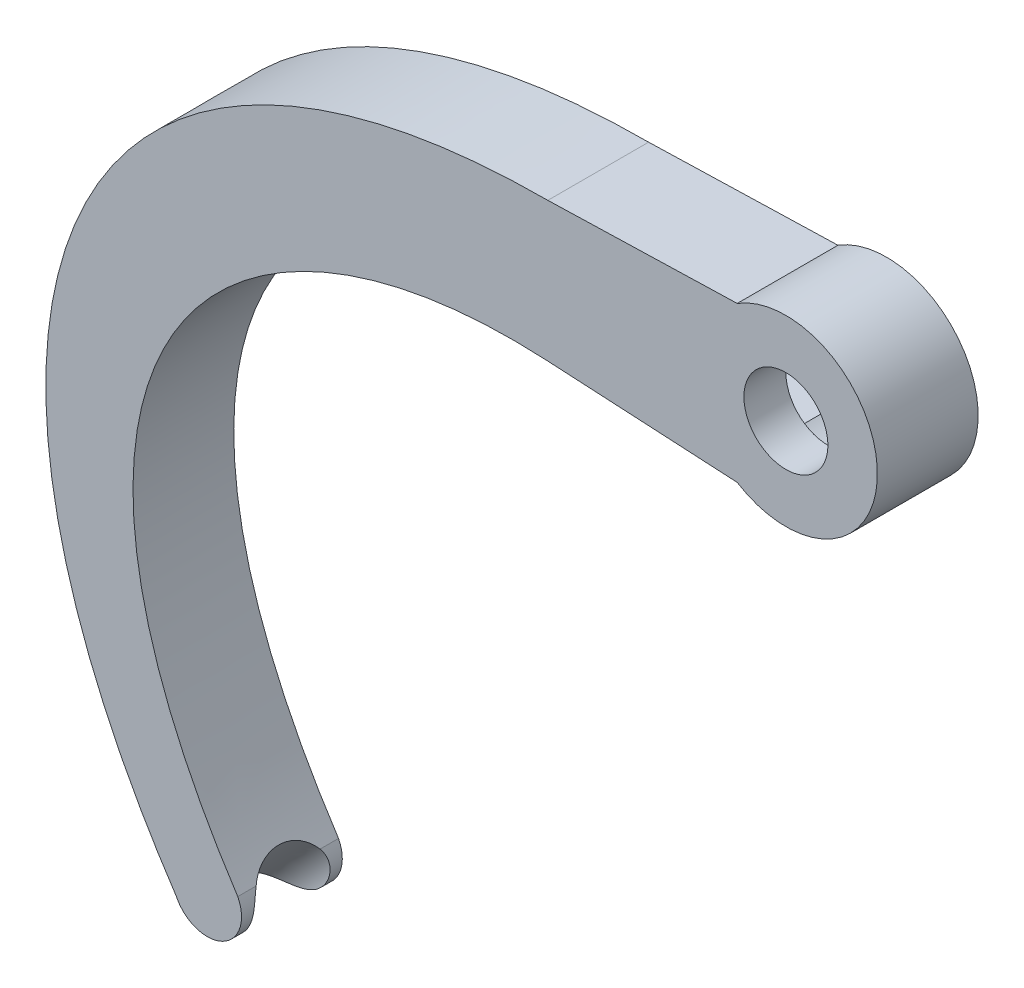
from build123d import *

# Parameters (mm, degrees)
BOSS_EXTRUDE1_DEPTH = 6
CUT_EXTRUDE1_DEPTH  = 3.5
SKETCH4_R           = 2.5
CUT_EXTRUDE2_DEPTH  = 3.5
SKETCH6_RX          = 2.368753343
SKETCH6_RY          = 2.322011883
CUT_EXTRUDE3_DEPTH  = 30


with BuildPart() as part:
    # Sketch1 → Boss-Extrude1 (new body)
    with BuildSketch(Plane.XY):
        with BuildLine():
            Line((-14.268243934, -3.994041761), (-2.898518265, -4.615310593))
            ThreePointArc((-2.898518265, -4.615310593), (5.45, 0), (-2.898518265, 4.615310593))
            Line((-2.898518265, 4.615310593), (-14.17529192, 4.292464798))
            add(Edge.make_bspline(
                [(-14.17529192, 4.292464798), (-42.462260129, 4.288818218), (-52.533757866, -18.372051692), (-36.302785322, -42.655354232)],
                knots=[0, 0, 0, 0, 1, 1, 1, 1], degree=3))
            ThreePointArc((-36.302785322, -42.655354232), (-33.552833422, -43.610103827), (-32.640753317, -40.845706583))
            add(Edge.make_bspline(
                [(-14.268243934, -3.994041761), (-34.73116579, -2.87481632), (-47.018413867, -18.971545605), (-32.640753317, -40.845706583)],
                knots=[0, 0, 0, 0, 1, 1, 1, 1], degree=3))
        make_face()
    extrude(amount=BOSS_EXTRUDE1_DEPTH)

    # Sketch3 → Cut-Extrude1 (cut)
    with BuildSketch(Plane.XY):
        with BuildLine():
            Line((-14.18094636, -2.396425056), (-2.359318085, -3.042386921))
            ThreePointArc((-2.359318085, -3.042386921), (3.85, 0), (-2.359318085, 3.042386921))
            Line((-2.359318085, 3.042386921), (-14.18094636, 2.396425056))
            ThreePointArc((-14.18094636, 2.396425056), (-16.45, 0), (-14.18094636, -2.396425056))
        make_face()
    extrude(amount=CUT_EXTRUDE1_DEPTH, mode=Mode.SUBTRACT)

    # Sketch4 → Cut-Extrude2 (cut)
    with BuildSketch(Plane(origin=(0, 0, 3.5), x_dir=(-1, 0, 0), z_dir=(0, 0, -1))):
        Circle(SKETCH4_R)
    extrude(amount=-CUT_EXTRUDE2_DEPTH, mode=Mode.SUBTRACT)

    # Sketch6 → Cut-Extrude3 (cut)
    with BuildSketch(Plane(origin=(-23.619287881, -25.215704234, 0), x_dir=(0, 0, -1), z_dir=(0.683626277, 0.72983225, 0))):
        with Locations(Location((-3, -5.45537074), (0, 0, -90))):
            Ellipse(SKETCH6_RX, SKETCH6_RY)
    extrude(amount=-CUT_EXTRUDE3_DEPTH, mode=Mode.SUBTRACT)


solid = part.part
